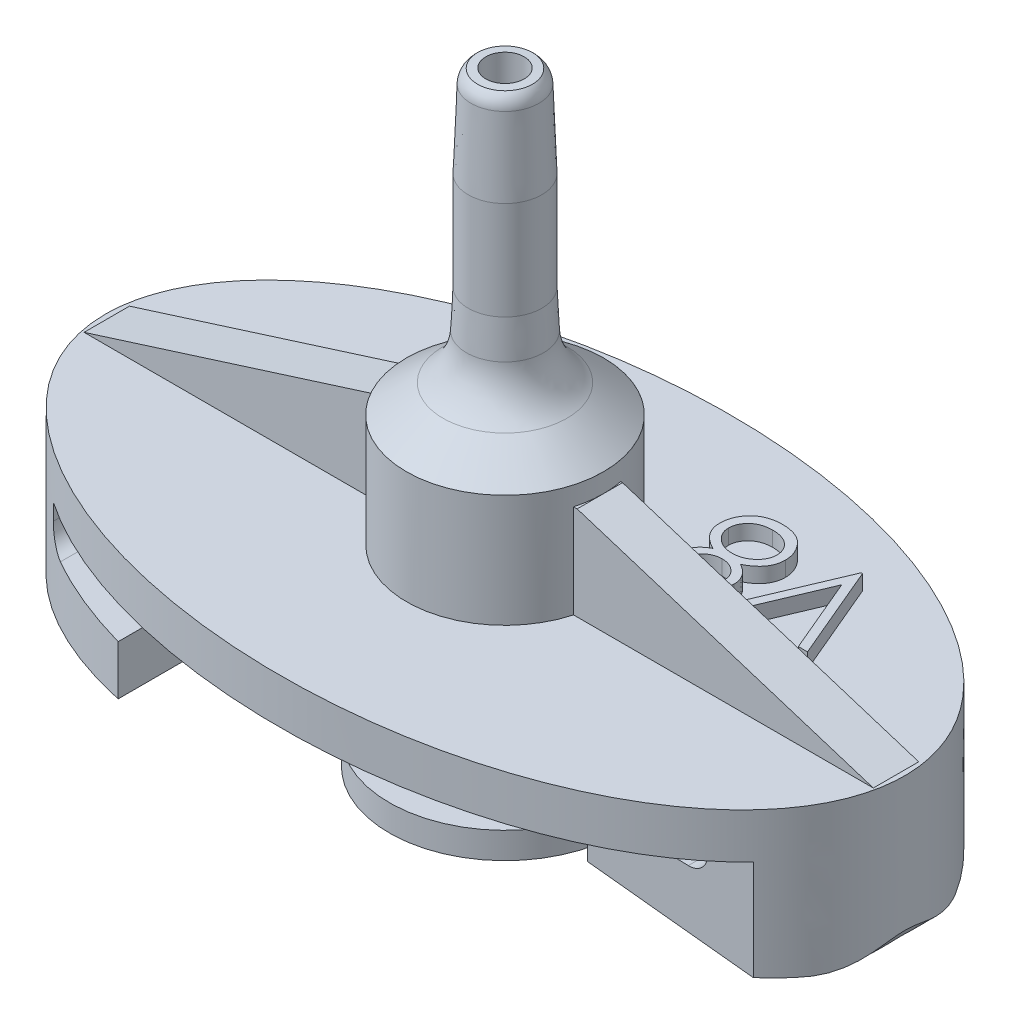
from build123d import *

# Parameters (mm, degrees)
SKETCH1_RX               = 26.6
SKETCH1_RY               = 15
BOSS_EXTRUDE1_DEPTH      = 3
BOSS_EXTRUDE4_DEPTH      = 1.75
BOSS_EXTRUDE4_DEPTH_BACK = 1.27
SKETCH4_R                = 1.27
CUT_EXTRUDE1_DEPTH       = 37.641813547
SKETCH5_R                = 3.5
CUT_EXTRUDE2_DEPTH       = 12
SKETCH7_R                = 3.5
CUT_EXTRUDE7_DEPTH       = 6.35
BOSS_EXTRUDE5_DEPTH      = 8
CUT_EXTRUDE13_DEPTH      = 37.080604342
CUT_EXTRUDE13_DEPTH_BACK = 37.080604342
BOSS_EXTRUDE6_DEPTH      = 1


with BuildPart() as part:
    # Sketch1 → Boss-Extrude1 (new body)
    with BuildSketch(Plane(origin=(0, 0, 0), x_dir=(1, 0, 0), z_dir=(0, 1, 0))):
        with Locations(Location((0, 0), (0, 0, -180))):
            Ellipse(SKETCH1_RX, SKETCH1_RY)
    extrude(amount=BOSS_EXTRUDE1_DEPTH)

    # Sketch2 → Revolve1 (revolve)
    with BuildSketch(Plane.XY):
        Polygon((0, 10.5), (0, -9.75), (7.7, -9.75), (7.7, -8), (5.9, -8), (5.9, 0), (10.45, 0), (10.45, 3), (6.551829244, 3), (6.551829244, 10.5), align=None)
    revolve(axis=Axis((0, 10.5, 0), (0, -1, 0)))

    # Sketch3 → Boss-Extrude4 (add, two sides: drawn at the far end of the back side and taken through both)
    with BuildSketch(Plane.XY.offset(-BOSS_EXTRUDE4_DEPTH_BACK)):
        Polygon((-6.551829244, 9.231580553), (-26.259541179, 3), (26.259541179, 3), (6.551829244, 9.231580553), align=None)
    extrude(amount=BOSS_EXTRUDE4_DEPTH + BOSS_EXTRUDE4_DEPTH_BACK)

    # Sketch4 → Cut-Extrude1 (cut, through all)
    with BuildSketch(Plane(origin=(0, 10.5, 0), x_dir=(1, 0, 0), z_dir=(0, 1, 0))):
        Circle(SKETCH4_R)
    extrude(amount=-CUT_EXTRUDE1_DEPTH, mode=Mode.SUBTRACT)

    # Sketch5 → Cut-Extrude2 (cut)
    with BuildSketch(Plane.XZ.offset(9.75)):
        Circle(SKETCH5_R)
    extrude(amount=-CUT_EXTRUDE2_DEPTH, mode=Mode.SUBTRACT)

    # Sketch7 → Cut-Extrude7 (cut)
    with BuildSketch(Plane.XZ.offset(-2.25)):
        Circle(SKETCH7_R)
    extrude(amount=-CUT_EXTRUDE7_DEPTH, mode=Mode.SUBTRACT)

    # Sketch8 → Boss-Extrude5 (add)
    with BuildSketch(Plane.XZ):
        with BuildLine():
            Line((12.5, 7), (23.52592518, 7))
            add(Edge.make_bspline(
                [(12.5, -13.2405967), (35.893568846, -6.217669253), (23.52592518, 7)],
                knots=[2.060001924, 2.060001924, 2.060001924, 3.627110776, 3.627110776, 3.627110776], degree=2, weights=[1, 0.708409298, 1]))
            Line((12.5, -13.2405967), (12.5, 7))
        make_face()
        with BuildLine():
            Line((-23.52592518, -7), (-12.5, -7))
            Line((-12.5, -7), (-12.5, 13.2405967))
            add(Edge.make_bspline(
                [(-12.5, 13.2405967), (-35.893568846, 6.217669253), (-23.52592518, -7)],
                knots=[5.201594578, 5.201594578, 5.201594578, 6.768703429, 6.768703429, 6.768703429], degree=2, weights=[1, 0.708409298, 1]))
        make_face()
    extrude(amount=BOSS_EXTRUDE5_DEPTH)

    # Sketch9 → Cut-Extrude13 (cut, two sides: drawn at the far end of the back side and taken through both)
    with BuildSketch(Plane.XY.offset(7).offset(-CUT_EXTRUDE13_DEPTH_BACK)):
        with BuildLine():
            Line((20.5, 0), (20.5, -1.106225021))
            ThreePointArc((20.5, -1.106225021), (20.116164757, -2.015956862), (19.19667398, -2.375787692))
            Line((19.19667398, -2.375787692), (12.5, -2.2))
            Line((12.5, -2.2), (12.5, 0))
            Line((12.5, 0), (20.5, 0))
        make_face()
        with BuildLine():
            Line((25.240246655, -6.853974858), (12.5, -5.5))
            Line((12.5, -5.5), (12.5, -8))
            Line((12.5, -8), (26.6, -8))
            Line((26.6, -8), (26.6, -5.915269448))
            add(Edge.make_bspline(
                [(26.6, -5.915269448), (26.22929668, -6.880231415), (25.240246655, -6.853974858)],
                knots=[0, 0, 0, 1, 1, 1], degree=2))
        make_face()
        with BuildLine():
            Line((-12.5, -8), (-26.6, -8))
            Line((-26.6, -8), (-26.6, -5.915269448))
            add(Edge.make_bspline(
                [(-26.6, -5.915269448), (-26.22929668, -6.880231415), (-25.240246655, -6.853974858)],
                knots=[0, 0, 0, 1, 1, 1], degree=2))
            Line((-25.240246655, -6.853974858), (-12.5, -5.5))
            Line((-12.5, -5.5), (-12.5, -8))
        make_face()
        with BuildLine():
            Line((-12.5, 0), (-20.5, 0))
            Line((-20.5, 0), (-20.5, -1.106225021))
            ThreePointArc((-20.5, -1.106225021), (-20.116164757, -2.015956862), (-19.19667398, -2.375787692))
            Line((-19.19667398, -2.375787692), (-12.5, -2.2))
            Line((-12.5, -2.2), (-12.5, 0))
        make_face()
    extrude(amount=CUT_EXTRUDE13_DEPTH + CUT_EXTRUDE13_DEPTH_BACK, mode=Mode.SUBTRACT)

    # 3DSketch1 → Revolve2 (revolve)
    with BuildSketch(Plane(origin=(1.278101811, 30.496368623, 0), x_dir=(0.25540088901820157, -0.9668352423700288, 0), z_dir=(0, 0, -1))):
        with BuildLine():
            Line((0, 0), (19.336704847, 5.10801778))
            Line((19.336704847, 5.10801778), (20.682350242, 0))
            Line((20.682350242, 0), (18.257770739, 1.876101401))
            ThreePointArc((18.257770739, 1.876101401), (16.69459074, 2.613515724), (14.966230504, 2.622598119))
            Line((14.966230504, 2.622598119), (12.511148394, 2.092869751))
            Line((12.511148394, 2.092869751), (6.186834728, 0.422227989))
            Line((6.186834728, 0.422227989), (1.140208913, -0.710129964))
            ThreePointArc((1.140208913, -0.710129964), (0.63556328, -0.717437509), (0.170314634, -0.521824852))
            Line((0.170314634, -0.521824852), (0, 0))
        make_face()
    revolve(axis=Axis((0, 0, 0), (0, 1, 0)))

    # Sketch10 → Boss-Extrude6 (add)
    # profile 1 of 2: a face of its own
    with BuildSketch(Plane(origin=(0, 3, -4.27), x_dir=(-1, 0, 0), z_dir=(0, 1, 0))):
        Polygon((-17.224100804, 1.363707883), (-16.613523881, 1.363707883), (-14.496857214, -3.640478816), (-12.380190547, 1.363707883), (-11.769613624, 1.363707883), (-14.456152086, -4.986292117), (-14.537562342, -4.986292117), align=None)
    # profile 2 of 2: a face of its own
    with BuildSketch(Plane(origin=(0, 3, -4.27), x_dir=(-1, 0, 0), z_dir=(0, 1, 0))):
        with BuildLine():
            add(Edge.make_bspline(
                [(-8.112512262, -1.448762069), (-8.060535612, -1.475863789), (-7.959163787, -1.528721194), (-7.814787995, -1.613830839), (-7.682844064, -1.703530875), (-7.559671187, -1.793584506), (-7.447433394, -1.887440502), (-7.347385673, -1.985472085), (-7.257056706, -2.0852323), (-7.178268112, -2.188410439), (-7.108968137, -2.294732388), (-7.049074691, -2.404477212), (-6.997880623, -2.517404403), (-6.957307863, -2.634746652), (-6.92388547, -2.754780269), (-6.900888301, -2.879055179), (-6.888520464, -3.006752483), (-6.886182188, -3.093054974), (-6.88499824, -3.136752854)],
                knots=[0, 0, 0, 0, 1.272397273, 2.481599622, 3.635517121, 4.734568067, 5.792894095, 6.808321871, 7.773003508, 8.711915296, 9.623354172, 10.525449501, 11.423591555, 12.311487226, 13.218079475, 14.126165749, 15.051214107, 16, 16, 16, 16], degree=3))
            add(Edge.make_bspline(
                [(-6.88499824, -3.136752854), (-6.886397817, -3.197890169), (-6.889168106, -3.318903855), (-6.913298077, -3.497513229), (-6.949425909, -3.670980319), (-7.002184453, -3.839267095), (-7.070607319, -4.001444958), (-7.154929578, -4.157652733), (-7.250381336, -4.310450622), (-7.32703897, -4.404465822), (-7.365827567, -4.452037309)],
                knots=[0, 0, 0, 0, 1.025265484, 2.029385089, 3.018602448, 3.995076438, 4.983346944, 5.966715145, 6.97116228, 8, 8, 8, 8], degree=3))
            add(Edge.make_bspline(
                [(-7.365827567, -4.452037309), (-7.416330884, -4.507543157), (-7.516713436, -4.61786895), (-7.688676748, -4.761108277), (-7.877402165, -4.881485035), (-8.082159426, -4.979586901), (-8.302401196, -5.055942673), (-8.538080547, -5.110811242), (-8.789656939, -5.142239078), (-8.962568293, -5.14678203), (-9.051274281, -5.14911263)],
                knots=[0, 0, 0, 0, 0.954267603, 1.896743057, 2.838368354, 3.796610408, 4.779680527, 5.799409237, 6.871065594, 8, 8, 8, 8], degree=3))
            add(Edge.make_bspline(
                [(-9.051274281, -5.14911263), (-9.136570001, -5.147021705), (-9.302546807, -5.142952979), (-9.544133242, -5.115385939), (-9.769327954, -5.067075381), (-9.979440325, -5.000954447), (-10.173203669, -4.914938747), (-10.350065867, -4.807880634), (-10.512578645, -4.684089303), (-10.655810104, -4.540009476), (-10.782970567, -4.385690193), (-10.894672606, -4.226483701), (-10.987517005, -4.062375467), (-11.066124736, -3.895812486), (-11.126301005, -3.724460178), (-11.167979158, -3.549200154), (-11.194448342, -3.370338538), (-11.197970116, -3.24963111), (-11.199741829, -3.1889063)],
                knots=[0, 0, 0, 0, 1.256902934, 2.445805442, 3.576955095, 4.645999104, 5.686449165, 6.692658513, 7.68621702, 8.689161843, 9.678783111, 10.630372946, 11.551080876, 12.453998257, 13.34127905, 14.221779781, 15.105423033, 16, 16, 16, 16], degree=3))
            add(Edge.make_bspline(
                [(-11.199741829, -3.1889063), (-11.198693388, -3.144348908), (-11.196621298, -3.056287776), (-11.182279645, -2.926186566), (-11.159222865, -2.799556436), (-11.127909279, -2.675929658), (-11.085471274, -2.556206264), (-11.034231975, -2.439818976), (-10.974484004, -2.326636396), (-10.905393891, -2.216039569), (-10.825017361, -2.109578169), (-10.734006168, -2.005445435), (-10.630541321, -1.905257191), (-10.515773854, -1.807789363), (-10.391015332, -1.711312953), (-10.253025241, -1.621041845), (-10.105461641, -1.530585252), (-10.00058612, -1.476504433), (-9.946787102, -1.448762069)],
                knots=[0, 0, 0, 0, 0.941657376, 1.861047343, 2.762797495, 3.66048619, 4.553285746, 5.444104102, 6.34607688, 7.256116206, 8.197091036, 9.162375105, 10.176350973, 11.237807142, 12.343728897, 13.50695164, 14.721116704, 16, 16, 16, 16], degree=3))
            add(Edge.make_bspline(
                [(-9.946787102, -1.448762069), (-10.020431453, -1.408603274), (-10.16302753, -1.330844608), (-10.35183923, -1.187975402), (-10.514019361, -1.033238938), (-10.645110063, -0.863367739), (-10.748292534, -0.68366841), (-10.819083431, -0.495265267), (-10.866974195, -0.301651746), (-10.871718239, -0.169379075), (-10.874100804, -0.102948768)],
                knots=[0, 0, 0, 0, 1.166880483, 2.259407225, 3.286803203, 4.280235371, 5.237608625, 6.161067461, 7.076446754, 8, 8, 8, 8], degree=3))
            add(Edge.make_bspline(
                [(-10.874100804, -0.102948768), (-10.871133677, -0.03528034), (-10.865169235, 0.100745), (-10.816939497, 0.303230395), (-10.738344519, 0.502106163), (-10.631444996, 0.696408385), (-10.498299618, 0.879560917), (-10.338558027, 1.043828063), (-10.156034903, 1.187721752), (-9.951641345, 1.308509951), (-9.731684174, 1.406814589), (-9.499608503, 1.474629728), (-9.259457866, 1.518963825), (-9.095994861, 1.523983327), (-9.013113224, 1.526528396)],
                knots=[0, 0, 0, 0, 0.888701115, 1.786444228, 2.72001202, 3.692817113, 4.693886446, 5.687152267, 6.695133018, 7.739871481, 8.800368666, 9.853104506, 10.91144658, 12, 12, 12, 12], degree=3))
            add(Edge.make_bspline(
                [(-9.013113224, 1.526528396), (-8.932370588, 1.523904316), (-8.773155309, 1.51872993), (-8.539122199, 1.475573737), (-8.315194207, 1.403493037), (-8.102143544, 1.305708075), (-7.903784299, 1.185263196), (-7.728520109, 1.039393039), (-7.573702425, 0.875850511), (-7.445642167, 0.692753517), (-7.340118067, 0.499197908), (-7.266637861, 0.296682763), (-7.219553566, 0.089583756), (-7.213614748, -0.050548051), (-7.210639265, -0.120757261)],
                knots=[0, 0, 0, 0, 1.072916533, 2.115669174, 3.151510826, 4.193348718, 5.225979165, 6.227137561, 7.216255879, 8.211077061, 9.189680878, 10.138522389, 11.067357538, 12, 12, 12, 12], degree=3))
            add(Edge.make_bspline(
                [(-7.210639265, -0.120757261), (-7.213241968, -0.18965778), (-7.218353529, -0.324974483), (-7.26135199, -0.522235455), (-7.333766145, -0.706969726), (-7.432634127, -0.881273511), (-7.561494654, -1.041985656), (-7.718627641, -1.191149823), (-7.902780323, -1.329991355), (-8.041139359, -1.408343758), (-8.112512262, -1.448762069)],
                knots=[0, 0, 0, 0, 0.975232327, 1.915300861, 2.843280834, 3.77672583, 4.742871857, 5.749627742, 6.839139064, 8, 8, 8, 8], degree=3))
        make_face()
        with BuildLine():
            add(Edge.make_bspline(
                [(-9.044914105, 0.875246345), (-9.089456281, 0.874064445), (-9.176600255, 0.871752134), (-9.304377986, 0.859671464), (-9.425884996, 0.836170627), (-9.542390805, 0.804894679), (-9.652298079, 0.762643615), (-9.757099485, 0.712941241), (-9.855011387, 0.652514522), (-9.947215751, 0.584730635), (-10.030220727, 0.510176362), (-10.103888985, 0.432500044), (-10.165081421, 0.350176118), (-10.217044577, 0.26525238), (-10.254748187, 0.175208334), (-10.282986281, 0.082804629), (-10.302075092, -0.013126425), (-10.303505456, -0.07868838), (-10.304229009, -0.111853014)],
                knots=[0, 0, 0, 0, 1.203892937, 2.355340988, 3.463153438, 4.544400666, 5.610487187, 6.640501085, 7.674077295, 8.714426146, 9.728707835, 10.68524104, 11.601827946, 12.495867327, 13.368432065, 14.231010473, 15.105153427, 16, 16, 16, 16], degree=3))
            add(Edge.make_bspline(
                [(-10.304229009, -0.111853014), (-10.302981929, -0.145019082), (-10.30051752, -0.210559995), (-10.281458216, -0.307344638), (-10.253052208, -0.402452464), (-10.208328865, -0.493621974), (-10.154687044, -0.584015783), (-10.08848108, -0.671374704), (-10.009579558, -0.756002759), (-9.920629773, -0.837180145), (-9.823725983, -0.913196473), (-9.721066362, -0.979187816), (-9.613939338, -1.034403988), (-9.503445584, -1.080358765), (-9.388458972, -1.116081937), (-9.269684084, -1.141425053), (-9.147100959, -1.157176676), (-9.064041905, -1.159058129), (-9.02201747, -1.160010066)],
                knots=[0, 0, 0, 0, 0.873023192, 1.725219244, 2.590779336, 3.480155217, 4.391973325, 5.357036234, 6.360879153, 7.436073238, 8.526419356, 9.601555421, 10.645666583, 11.697338044, 12.750135903, 13.812665442, 14.89329948, 16, 16, 16, 16], degree=3))
            add(Edge.make_bspline(
                [(-9.02201747, -1.160010066), (-8.968042282, -1.158426435), (-8.860625015, -1.155274816), (-8.702275371, -1.125971972), (-8.548310287, -1.079878379), (-8.400375418, -1.016813868), (-8.262299956, -0.937660465), (-8.139218689, -0.842894847), (-8.03218147, -0.734705185), (-7.942300648, -0.614775754), (-7.872614212, -0.487137873), (-7.81836379, -0.35904877), (-7.786684156, -0.229141865), (-7.782551999, -0.142116088), (-7.78051106, -0.099132662)],
                knots=[0, 0, 0, 0, 1.076279235, 2.141928126, 3.20205304, 4.278698113, 5.344010996, 6.36967002, 7.368914609, 8.37248503, 9.349703398, 10.264243087, 11.142681841, 12, 12, 12, 12], degree=3))
            add(Edge.make_bspline(
                [(-7.78051106, -0.099132662), (-7.781476074, -0.068964654), (-7.783391489, -0.009085482), (-7.799175876, 0.079339838), (-7.825257745, 0.165753511), (-7.860569333, 0.250869402), (-7.907032818, 0.333493302), (-7.962122129, 0.414924047), (-8.029041153, 0.49332979), (-8.104146111, 0.570537714), (-8.189318495, 0.641991585), (-8.284394165, 0.704828845), (-8.388885683, 0.758191264), (-8.502795521, 0.80153229), (-8.625704169, 0.834084839), (-8.757045527, 0.858462213), (-8.897914738, 0.872202001), (-8.994851572, 0.874209554), (-9.044914105, 0.875246345)],
                knots=[0, 0, 0, 0, 0.814439003, 1.616544685, 2.417341072, 3.248991801, 4.09997495, 4.973547432, 5.9003056, 6.880240646, 7.880314356, 8.896779544, 9.951930927, 11.043077905, 12.18215768, 13.381699519, 14.647792085, 16, 16, 16, 16], degree=3))
        make_face(mode=Mode.SUBTRACT)
        with BuildLine():
            add(Edge.make_bspline(
                [(-9.008025083, -1.811292117), (-9.064496151, -1.812296581), (-9.175278607, -1.814267093), (-9.337579034, -1.836200901), (-9.493341206, -1.866734228), (-9.642039948, -1.913054464), (-9.783612466, -1.973282382), (-9.918825161, -2.045735047), (-10.046643639, -2.131379209), (-10.165302872, -2.229126782), (-10.273658055, -2.33446322), (-10.368723542, -2.445973094), (-10.449454758, -2.561583975), (-10.514466513, -2.682764162), (-10.567827798, -2.806947685), (-10.60286869, -2.937227179), (-10.625332652, -3.071098085), (-10.628349141, -3.162102835), (-10.629870035, -3.207986828)],
                knots=[0, 0, 0, 0, 1.140299081, 2.23698856, 3.303958914, 4.344563908, 5.37730929, 6.408454204, 7.439741482, 8.480804886, 9.510774543, 10.48932336, 11.43758569, 12.353841022, 13.263987381, 14.161954604, 15.073269652, 16, 16, 16, 16], degree=3))
            add(Edge.make_bspline(
                [(-10.629870035, -3.207986828), (-10.627396694, -3.265011472), (-10.622489643, -3.378147034), (-10.58356117, -3.545357177), (-10.52108527, -3.707229662), (-10.433953806, -3.862445348), (-10.326062639, -4.007497684), (-10.193390333, -4.133933034), (-10.044181956, -4.246276288), (-9.873388992, -4.337136684), (-9.686828775, -4.409698778), (-9.484550924, -4.459693168), (-9.269458429, -4.49278837), (-9.12094174, -4.496123356), (-9.044914105, -4.497830578)],
                knots=[0, 0, 0, 0, 0.898778495, 1.783155532, 2.693654817, 3.627872908, 4.583023416, 5.533784346, 6.509005473, 7.520592997, 8.575161974, 9.658835044, 10.801527049, 12, 12, 12, 12], degree=3))
            add(Edge.make_bspline(
                [(-9.044914105, -4.497830578), (-8.98549558, -4.49668974), (-8.86972924, -4.494467022), (-8.700844733, -4.474846802), (-8.541469623, -4.443732483), (-8.391912975, -4.398477764), (-8.25050058, -4.343232807), (-8.119630066, -4.272163459), (-7.995934738, -4.191332816), (-7.88550983, -4.095433017), (-7.784938151, -3.992963077), (-7.697247749, -3.884486856), (-7.621124763, -3.772952494), (-7.561378601, -3.655839472), (-7.513615255, -3.535394641), (-7.47928252, -3.410507357), (-7.458098529, -3.280794577), (-7.455956047, -3.192803405), (-7.454870035, -3.148201171)],
                knots=[0, 0, 0, 0, 1.224942928, 2.386581632, 3.501229538, 4.569074225, 5.605009692, 6.626002462, 7.634866581, 8.645888296, 9.63523824, 10.59253846, 11.518950513, 12.414518923, 13.29783783, 14.186679152, 15.080837789, 16, 16, 16, 16], degree=3))
            add(Edge.make_bspline(
                [(-7.454870035, -3.148201171), (-7.456513503, -3.104880854), (-7.459754135, -3.019460754), (-7.480322132, -2.892884341), (-7.516455223, -2.770596378), (-7.566034929, -2.651125653), (-7.63204039, -2.536892871), (-7.709773225, -2.424922103), (-7.803561126, -2.318321125), (-7.909538265, -2.216261937), (-8.025033808, -2.121890529), (-8.147801342, -2.03840719), (-8.276895866, -1.968099779), (-8.412044206, -1.910919852), (-8.552946272, -1.8659483), (-8.699498427, -1.834532137), (-8.851872256, -1.814757143), (-8.955386093, -1.812460175), (-9.008025083, -1.811292117)],
                knots=[0, 0, 0, 0, 0.917430815, 1.809013306, 2.70690318, 3.612392954, 4.541220862, 5.495268465, 6.494511384, 7.542276156, 8.608045339, 9.649016899, 10.681629292, 11.715607085, 12.752076957, 13.808767841, 14.885711793, 16, 16, 16, 16], degree=3))
        make_face(mode=Mode.SUBTRACT)
    extrude(amount=BOSS_EXTRUDE6_DEPTH)


solid = part.part
